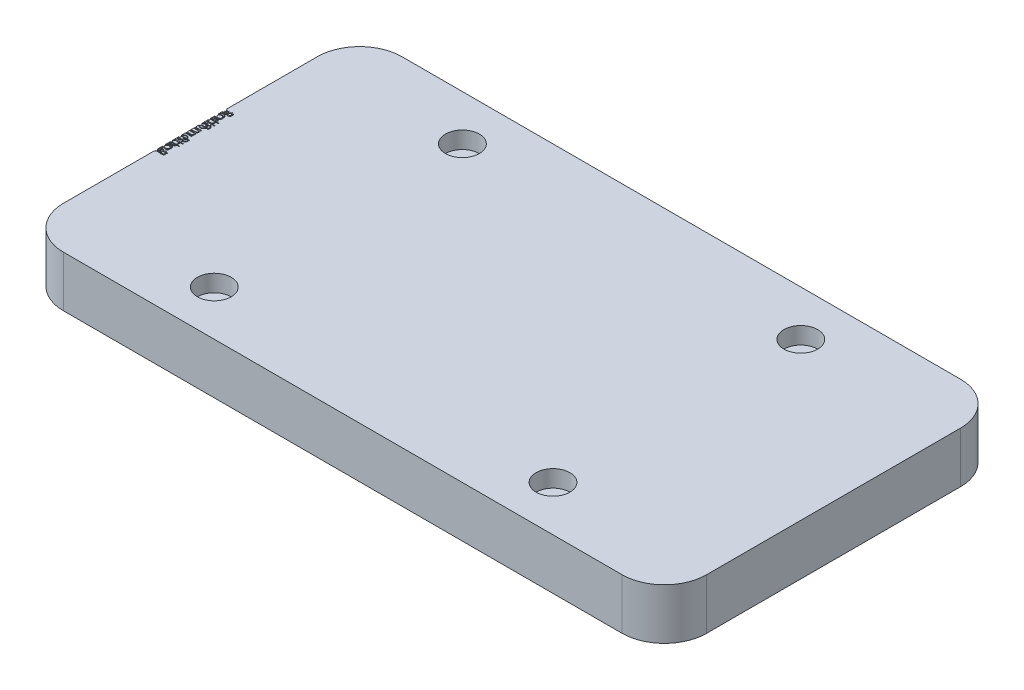
from build123d import *

# Parameters (mm, degrees)
SKETCH1_W           = 965.2
SKETCH1_H           = 508
BOSS_EXTRUDE1_DEPTH = 76.2
FILLET1_R           = 63.5
SKETCH3_R           = 25.4
CUT_EXTRUDE2_DEPTH  = 25.4


with BuildPart() as part:
    # Sketch1 → Boss-Extrude1 (new body)
    with BuildSketch(Plane(origin=(0, 0, 0), x_dir=(1, 0, 0), z_dir=(0, 1, 0))):
        Rectangle(SKETCH1_W, SKETCH1_H)
    extrude(amount=BOSS_EXTRUDE1_DEPTH)

    # Fillet1
    fillet1_edges = [part.edges().sort_by_distance(p)[0] for p in [
        (482.6, 38.1, 254),
        (-482.6, 38.1, 254),
        (-482.6, 38.1, -254),
        (482.6, 38.1, -254),
    ]]
    fillet(fillet1_edges, radius=FILLET1_R)

    # Sketch3 → Cut-Extrude2 (cut)
    with BuildSketch(Plane(origin=(0, 76.2, 0), x_dir=(1, 0, 0), z_dir=(0, 1, 0))):
        with Locations((-260.576021006, -186.128451286)):
            Circle(SKETCH3_R)
        with Locations((247.423936981, -185.921848446)):
            Circle(SKETCH3_R)
        with BuildLine():
            Line((-469.9, 52.672435897), (-469.9, 50.194511218))
            add(Edge.make_bspline(
                [(-469.9, 50.194511218), (-469.900637723, 50.073213597), (-469.901873789, 49.83810862), (-469.921044007, 49.496226645), (-469.947183038, 49.176009532), (-469.988657946, 48.877364415), (-470.038702394, 48.600429295), (-470.099306127, 48.344369583), (-470.171974125, 48.109999529), (-470.287530631, 47.830190457), (-470.459246128, 47.511164059), (-470.712986921, 47.165729891), (-471.023347573, 46.870348794), (-471.37344178, 46.615672729), (-471.758563009, 46.41319438), (-472.169532065, 46.266711502), (-472.6010481, 46.173972925), (-472.897296203, 46.164435464), (-473.047015224, 46.159615385)],
                knots=[0, 0, 0, 0, 0.000363838, 0.000705208, 0.00102698, 0.001327407, 0.00160934, 0.001870971, 0.002116378, 0.002344566, 0.002778261, 0.003200071, 0.003624679, 0.004058247, 0.004495235, 0.00492495, 0.005364021, 0.005812651, 0.005812651, 0.005812651, 0.005812651], degree=3))
            add(Edge.make_bspline(
                [(-473.047015224, 46.159615385), (-473.187292547, 46.163505539), (-473.462950716, 46.171150059), (-473.86548182, 46.246739197), (-474.250235763, 46.359280642), (-474.612469325, 46.522657567), (-474.947527019, 46.732810851), (-475.253417612, 46.985706072), (-475.5227281, 47.286810892), (-475.672659667, 47.512768065), (-475.748818109, 47.627544071)],
                knots=[0, 0, 0, 0, 0.000420396, 0.000826117, 0.00122453, 0.001620785, 0.002013965, 0.002407779, 0.002807724, 0.003220601, 0.003220601, 0.003220601, 0.003220601], degree=3))
            add(Edge.make_bspline(
                [(-475.748818109, 47.627544071), (-475.804165504, 47.483246357), (-475.91005878, 47.207169085), (-476.09829553, 46.826977114), (-476.300723621, 46.498102621), (-476.522955272, 46.220183613), (-476.765492883, 45.986079858), (-477.02347977, 45.775849827), (-477.30961699, 45.599724195), (-477.615756983, 45.448417432), (-477.939751109, 45.329340595), (-478.280117616, 45.24508592), (-478.63305059, 45.193315523), (-478.873610275, 45.186256112), (-478.995052083, 45.182692308)],
                knots=[0, 0, 0, 0, 0.000463447, 0.000886689, 0.0012707, 0.001619943, 0.001950965, 0.002280342, 0.002616352, 0.002956544, 0.003303444, 0.003649597, 0.004006864, 0.004371102, 0.004371102, 0.004371102, 0.004371102], degree=3))
            add(Edge.make_bspline(
                [(-478.995052083, 45.182692308), (-479.119028316, 45.186237976), (-479.362955028, 45.193214177), (-479.721305128, 45.244651328), (-480.063714462, 45.331828482), (-480.392617608, 45.451614654), (-480.70615286, 45.60883896), (-481.008246984, 45.796052137), (-481.290852396, 46.023914301), (-481.560689765, 46.277898937), (-481.803163144, 46.565563859), (-482.019031781, 46.875886763), (-482.197376027, 47.213331113), (-482.345316936, 47.572664039), (-482.459970385, 47.956273322), (-482.539568126, 48.362736629), (-482.593326065, 48.792142289), (-482.597737607, 49.086819793), (-482.6, 49.237940705)],
                knots=[0, 0, 0, 0, 0.000371861, 0.000731647, 0.001083355, 0.001430255, 0.001779543, 0.002133891, 0.002494262, 0.002866749, 0.003243967, 0.003620798, 0.003998668, 0.004386545, 0.004784958, 0.005197576, 0.005627998, 0.006081099, 0.006081099, 0.006081099, 0.006081099], degree=3))
            Line((-482.6, 49.237940705), (-482.6, 52.672435897))
            Line((-482.6, 52.672435897), (-469.9, 52.672435897))
        make_face()
        with BuildLine():
            Line((-471.202564103, 51.532692308), (-475.273076923, 51.532692308))
            Line((-475.273076923, 51.532692308), (-475.273076923, 50.766927083))
            add(Edge.make_bspline(
                [(-475.273076923, 50.766927083), (-475.27163785, 50.654989018), (-475.268857267, 50.438701864), (-475.260641171, 50.124651579), (-475.238643183, 49.833867594), (-475.215376682, 49.565347919), (-475.179551031, 49.32089229), (-475.1357105, 49.099682337), (-475.089750465, 48.8997309), (-475.011368955, 48.669247787), (-474.896703811, 48.407882991), (-474.714568466, 48.131029112), (-474.503524996, 47.882997153), (-474.255517346, 47.675893594), (-473.984747936, 47.504996957), (-473.691192628, 47.390947958), (-473.386311721, 47.310054501), (-473.176458844, 47.30296067), (-473.069911859, 47.299358974)],
                knots=[0, 0, 0, 0, 0.000335856, 0.000648942, 0.000942217, 0.001210553, 0.001457367, 0.001682887, 0.001887127, 0.002072164, 0.002412623, 0.002740048, 0.003062904, 0.003386041, 0.003705876, 0.004018621, 0.004327755, 0.004646587, 0.004646587, 0.004646587, 0.004646587], degree=3))
            add(Edge.make_bspline(
                [(-473.069911859, 47.299358974), (-472.999390861, 47.301160334), (-472.861056222, 47.304693898), (-472.660172947, 47.336853528), (-472.468824541, 47.383517465), (-472.291411885, 47.456420771), (-472.122892405, 47.544575936), (-471.970751178, 47.659249808), (-471.826653001, 47.788755491), (-471.695888802, 47.94084731), (-471.578723568, 48.114788827), (-471.475628439, 48.312237386), (-471.394304052, 48.535550624), (-471.321351749, 48.779665166), (-471.270730801, 49.048487848), (-471.228404946, 49.339391905), (-471.206889543, 49.654845166), (-471.204038075, 49.873085331), (-471.202564103, 49.985897436)],
                knots=[0, 0, 0, 0, 0.000211403, 0.00041469, 0.000609058, 0.000800861, 0.000988675, 0.001177964, 0.00137066, 0.001569065, 0.001777927, 0.001998675, 0.002235397, 0.002489804, 0.002762221, 0.003055088, 0.003371383, 0.00370983, 0.00370983, 0.00370983, 0.00370983], degree=3))
            Line((-471.202564103, 49.985897436), (-471.202564103, 51.532692308))
        make_face(mode=Mode.SUBTRACT)
        with BuildLine():
            Line((-476.575641026, 51.532692308), (-481.297435897, 51.532692308))
            Line((-481.297435897, 51.532692308), (-481.297435897, 49.909575321))
            add(Edge.make_bspline(
                [(-481.297435897, 49.909575321), (-481.296048306, 49.793391785), (-481.293373906, 49.569463336), (-481.284547792, 49.246160825), (-481.264893346, 48.947317605), (-481.232851357, 48.672761709), (-481.199556938, 48.420076298), (-481.153475853, 48.191771808), (-481.101087231, 47.98749823), (-481.020013357, 47.750667938), (-480.894278648, 47.483810583), (-480.703462766, 47.196432078), (-480.479128443, 46.938377978), (-480.21621688, 46.721754486), (-479.932509836, 46.5428753), (-479.629491192, 46.41741689), (-479.316405145, 46.33674893), (-479.102385409, 46.327216513), (-478.995052083, 46.322435897)],
                knots=[0, 0, 0, 0, 0.000348575, 0.000671832, 0.000970183, 0.001246634, 0.001501003, 0.001734503, 0.001944924, 0.002133185, 0.002484838, 0.002826351, 0.003165238, 0.003506608, 0.003844778, 0.004167484, 0.004487107, 0.004808668, 0.004808668, 0.004808668, 0.004808668], degree=3))
            add(Edge.make_bspline(
                [(-478.995052083, 46.322435897), (-478.927938995, 46.32341304), (-478.794795357, 46.325351565), (-478.599284527, 46.355686208), (-478.409054527, 46.398005015), (-478.226981914, 46.459286285), (-478.050103978, 46.536557), (-477.881501654, 46.633528815), (-477.717143599, 46.74551289), (-477.509596623, 46.920692987), (-477.270385861, 47.175255019), (-477.036215676, 47.537068916), (-476.847354019, 47.94844254), (-476.767164842, 48.246811706), (-476.725741186, 48.400941506)],
                knots=[0, 0, 0, 0, 0.000201126, 0.000399009, 0.000592174, 0.000785255, 0.00097434, 0.001170299, 0.001367887, 0.001570168, 0.001984172, 0.002410363, 0.00285778, 0.003335876, 0.003335876, 0.003335876, 0.003335876], degree=3))
            add(Edge.make_bspline(
                [(-476.725741186, 48.400941506), (-476.713203324, 48.462732739), (-476.686018654, 48.596708878), (-476.657341193, 48.815177494), (-476.631616576, 49.065426833), (-476.613087666, 49.346387285), (-476.593197204, 49.659176266), (-476.585737067, 50.00369329), (-476.576631577, 50.380181916), (-476.575979656, 50.641411701), (-476.575641026, 50.777103365)],
                knots=[0, 0, 0, 0, 0.000189102, 0.000410011, 0.000660625, 0.000943749, 0.001254636, 0.001600779, 0.001977379, 0.002384439, 0.002384439, 0.002384439, 0.002384439], degree=3))
            Line((-476.575641026, 50.777103365), (-476.575641026, 51.532692308))
        make_face(mode=Mode.SUBTRACT)
        with BuildLine():
            add(Edge.make_bspline(
                [(-473.156410256, 38.420552885), (-473.16010738, 38.2464088), (-473.167356535, 37.90495481), (-473.245216359, 37.404970266), (-473.363285809, 36.928198741), (-473.529483921, 36.472595029), (-473.747542335, 36.04192789), (-474.011239846, 35.632352177), (-474.322360513, 35.244688492), (-474.563165778, 35.012386046), (-474.685396635, 34.894471154)],
                knots=[0, 0, 0, 0, 0.000522037, 0.001023587, 0.001514124, 0.001993828, 0.002475095, 0.002959197, 0.003453068, 0.003962168, 0.003962168, 0.003962168, 0.003962168], degree=3))
            add(Edge.make_bspline(
                [(-474.685396635, 34.894471154), (-474.802287383, 34.792936635), (-475.033806722, 34.591832569), (-475.409202803, 34.333965533), (-475.797968311, 34.111818729), (-476.205265754, 33.93379027), (-476.62753956, 33.793418899), (-477.066241144, 33.693757658), (-477.520401661, 33.634477922), (-477.828844159, 33.6264843), (-477.98505609, 33.622435897)],
                knots=[0, 0, 0, 0, 0.000464173, 0.000919362, 0.001363665, 0.001805638, 0.002250531, 0.002696738, 0.003153347, 0.003621898, 0.003621898, 0.003621898, 0.003621898], degree=3))
            add(Edge.make_bspline(
                [(-477.98505609, 33.622435897), (-478.142173442, 33.62599675), (-478.452644658, 33.63303316), (-478.909914924, 33.699594284), (-479.35330758, 33.803121361), (-479.78096622, 33.951282625), (-480.194198376, 34.141267681), (-480.591198043, 34.373099921), (-480.972752756, 34.648404287), (-481.335606158, 34.960480646), (-481.670076683, 35.305365585), (-481.96141292, 35.679593572), (-482.212062, 36.07608169), (-482.411147062, 36.500242393), (-482.571623488, 36.946037888), (-482.682282312, 37.416303713), (-482.749787197, 37.910620352), (-482.758414963, 38.248184379), (-482.762820513, 38.420552885)],
                knots=[0, 0, 0, 0, 0.000471093, 0.000930902, 0.001383217, 0.001835375, 0.002286164, 0.002745627, 0.00321231, 0.003695764, 0.00417976, 0.00465101, 0.005116193, 0.005583894, 0.006053824, 0.006535131, 0.007030572, 0.007547526, 0.007547526, 0.007547526, 0.007547526], degree=3))
            add(Edge.make_bspline(
                [(-482.762820513, 38.420552885), (-482.758378512, 38.593757604), (-482.749678628, 38.932987796), (-482.682784452, 39.429165746), (-482.570441145, 39.901411537), (-482.413133726, 40.349315748), (-482.210426778, 40.773474731), (-481.962388173, 41.171426887), (-481.669929156, 41.545831391), (-481.335646131, 41.890824457), (-480.972742457, 42.202871825), (-480.591200716, 42.478183672), (-480.19419768, 42.710013968), (-479.780966406, 42.899999534), (-479.35330753, 43.048160661), (-478.909914938, 43.151687775), (-478.452644654, 43.218248889), (-478.142173441, 43.225285301), (-477.98505609, 43.228846154)],
                knots=[0, 0, 0, 0, 0.000519495, 0.001017458, 0.001498765, 0.001973491, 0.002438896, 0.002906237, 0.003377488, 0.003861484, 0.004344937, 0.00481162, 0.005271084, 0.005721873, 0.006174031, 0.006626346, 0.007086155, 0.007557247, 0.007557247, 0.007557247, 0.007557247], degree=3))
            add(Edge.make_bspline(
                [(-477.98505609, 43.228846154), (-477.829693195, 43.224770142), (-477.522101363, 43.216700339), (-477.0687946, 43.157480206), (-476.630835503, 43.05820773), (-476.210191633, 42.917668091), (-475.80467905, 42.737998684), (-475.414952949, 42.518973439), (-475.041254359, 42.258476001), (-474.81003424, 42.058171777), (-474.693028846, 41.956810897)],
                knots=[0, 0, 0, 0, 0.00046601, 0.000922619, 0.001368826, 0.001811304, 0.00225095, 0.002697469, 0.003150571, 0.003614743, 0.003614743, 0.003614743, 0.003614743], degree=3))
            add(Edge.make_bspline(
                [(-474.693028846, 41.956810897), (-474.569758563, 41.839064017), (-474.32732586, 41.607494057), (-474.016819049, 41.218040861), (-473.749566262, 40.810227001), (-473.531617589, 40.376781912), (-473.363587363, 39.91991136), (-473.244665292, 39.439596373), (-473.16770093, 38.937791986), (-473.160211321, 38.594684168), (-473.156410256, 38.420552885)],
                knots=[0, 0, 0, 0, 0.000510896, 0.001004767, 0.001490251, 0.001971518, 0.002456876, 0.002947413, 0.003453996, 0.003976033, 0.003976033, 0.003976033, 0.003976033], degree=3))
        make_face()
        with BuildLine():
            add(Edge.make_bspline(
                [(-474.296153846, 38.425641026), (-474.299654125, 38.548785934), (-474.306564324, 38.791896785), (-474.359117476, 39.149746988), (-474.442394232, 39.494236739), (-474.560663151, 39.826063577), (-474.713562546, 40.143944109), (-474.900302429, 40.448228095), (-475.121877393, 40.738098032), (-475.373883427, 41.011327095), (-475.647606173, 41.26502737), (-475.941941749, 41.484244379), (-476.24844624, 41.670992851), (-476.568710633, 41.826402283), (-476.905767983, 41.942190335), (-477.255857398, 42.026272442), (-477.619676934, 42.078779516), (-477.867004152, 42.085624269), (-477.992688301, 42.089102564)],
                knots=[0, 0, 0, 0, 0.00036932, 0.000729106, 0.001082667, 0.001431094, 0.00178384, 0.002139009, 0.002500276, 0.002876601, 0.003252925, 0.003618254, 0.003975594, 0.00432834, 0.004683965, 0.005042471, 0.005407295, 0.005784238, 0.005784238, 0.005784238, 0.005784238], degree=3))
            add(Edge.make_bspline(
                [(-477.992688301, 42.089102564), (-478.155081404, 42.083287475), (-478.477401347, 42.071745611), (-478.951953328, 41.977411514), (-479.408393042, 41.820718181), (-479.841224834, 41.604648572), (-480.242390724, 41.338552349), (-480.603120985, 41.027407388), (-480.90950441, 40.666912005), (-481.167178029, 40.269341758), (-481.370095762, 39.840330724), (-481.51561476, 39.387071454), (-481.608937334, 38.913691013), (-481.618322478, 38.589748136), (-481.623076923, 38.425641026)],
                knots=[0, 0, 0, 0, 0.000486876, 0.000966357, 0.001445055, 0.001930872, 0.002413502, 0.002885933, 0.003355036, 0.003827829, 0.004303516, 0.004774169, 0.005253171, 0.005744974, 0.005744974, 0.005744974, 0.005744974], degree=3))
            add(Edge.make_bspline(
                [(-481.623076923, 38.425641026), (-481.618350018, 38.261524476), (-481.60901924, 37.937562966), (-481.515141956, 37.463523876), (-481.37072853, 37.009022368), (-481.166948845, 36.579565272), (-480.910478348, 36.181813971), (-480.601375547, 35.823892772), (-480.243339018, 35.510068273), (-479.841756752, 35.243708566), (-479.407720151, 35.031120436), (-478.952037431, 34.873690221), (-478.477379928, 34.779582363), (-478.155074228, 34.768009962), (-477.992688301, 34.762179487)],
                knots=[0, 0, 0, 0, 0.000491802, 0.000970804, 0.001443878, 0.001919565, 0.002392359, 0.002859533, 0.003333639, 0.003816269, 0.004300959, 0.004779657, 0.005259139, 0.005746014, 0.005746014, 0.005746014, 0.005746014], degree=3))
            add(Edge.make_bspline(
                [(-477.992688301, 34.762179487), (-477.866994116, 34.765631901), (-477.61964715, 34.772425726), (-477.255971253, 34.825303231), (-476.905075553, 34.908079203), (-476.570068953, 35.028937645), (-476.246882051, 35.179013335), (-475.942862132, 35.37030468), (-475.647419061, 35.58850062), (-475.374048409, 35.842666429), (-475.12095662, 36.115864731), (-474.901109577, 36.407912331), (-474.713455907, 36.712337635), (-474.560644321, 37.030318625), (-474.442849452, 37.361394555), (-474.35875471, 37.704838417), (-474.306755938, 38.061103889), (-474.29971048, 38.303351474), (-474.296153846, 38.425641026)],
                knots=[0, 0, 0, 0, 0.000376943, 0.000741767, 0.001100273, 0.001456743, 0.001808396, 0.002167065, 0.002532393, 0.002908718, 0.003285043, 0.003648338, 0.004003507, 0.004356253, 0.004704679, 0.00505577, 0.005415556, 0.005782335, 0.005782335, 0.005782335, 0.005782335], degree=3))
        make_face(mode=Mode.SUBTRACT)
        Polygon((-469.574358974, 30.203205128), (-469.574358974, 29.063461538), (-473.319230769, 29.063461538), (-473.319230769, 27.43525641), (-474.458974359, 27.43525641), (-474.458974359, 29.063461538), (-482.6, 29.063461538), (-482.6, 30.203205128), (-474.458974359, 30.203205128), (-474.458974359, 31.831410256), (-473.319230769, 31.831410256), (-473.319230769, 30.203205128), align=None)
        Polygon((-469.574358974, 24.178846154), (-469.574358974, 23.039102564), (-473.319230769, 23.039102564), (-473.319230769, 21.410897436), (-474.458974359, 21.410897436), (-474.458974359, 23.039102564), (-482.6, 23.039102564), (-482.6, 24.178846154), (-474.458974359, 24.178846154), (-474.458974359, 25.807051282), (-473.319230769, 25.807051282), (-473.319230769, 24.178846154), align=None)
        with BuildLine():
            add(Edge.make_bspline(
                [(-473.156410256, 14.811578526), (-473.16010738, 14.637434441), (-473.167356535, 14.295980451), (-473.245216359, 13.795995907), (-473.363285809, 13.319224382), (-473.529483921, 12.86362067), (-473.747542335, 12.432953531), (-474.011239846, 12.023377818), (-474.322360513, 11.635714133), (-474.563165778, 11.403411687), (-474.685396635, 11.285496795)],
                knots=[0, 0, 0, 0, 0.000522037, 0.001023587, 0.001514124, 0.001993828, 0.002475095, 0.002959197, 0.003453068, 0.003962168, 0.003962168, 0.003962168, 0.003962168], degree=3))
            add(Edge.make_bspline(
                [(-474.685396635, 11.285496795), (-474.802287383, 11.183962276), (-475.033806722, 10.98285821), (-475.409202803, 10.724991174), (-475.797968311, 10.50284437), (-476.205265754, 10.324815911), (-476.62753956, 10.18444454), (-477.066241144, 10.084783299), (-477.520401661, 10.025503564), (-477.828844159, 10.017509941), (-477.98505609, 10.013461538)],
                knots=[0, 0, 0, 0, 0.000464173, 0.000919362, 0.001363665, 0.001805638, 0.002250531, 0.002696738, 0.003153347, 0.003621898, 0.003621898, 0.003621898, 0.003621898], degree=3))
            add(Edge.make_bspline(
                [(-477.98505609, 10.013461538), (-478.142173442, 10.017022391), (-478.452644658, 10.024058801), (-478.909914924, 10.090619925), (-479.35330758, 10.194147002), (-479.78096622, 10.342308266), (-480.194198376, 10.532293322), (-480.591198043, 10.764125562), (-480.972752756, 11.039429928), (-481.335606158, 11.351506287), (-481.670076683, 11.696391226), (-481.96141292, 12.070619213), (-482.212062, 12.467107331), (-482.411147062, 12.891268034), (-482.571623488, 13.337063529), (-482.682282312, 13.807329354), (-482.749787197, 14.301645993), (-482.758414963, 14.63921002), (-482.762820513, 14.811578526)],
                knots=[0, 0, 0, 0, 0.000471093, 0.000930902, 0.001383217, 0.001835375, 0.002286164, 0.002745627, 0.00321231, 0.003695764, 0.00417976, 0.00465101, 0.005116193, 0.005583894, 0.006053824, 0.006535131, 0.007030572, 0.007547526, 0.007547526, 0.007547526, 0.007547526], degree=3))
            add(Edge.make_bspline(
                [(-482.762820513, 14.811578526), (-482.758378512, 14.984783245), (-482.749678628, 15.324013437), (-482.682784452, 15.820191387), (-482.570441145, 16.292437178), (-482.413133726, 16.740341389), (-482.210426778, 17.164500372), (-481.962388173, 17.562452528), (-481.669929156, 17.936857032), (-481.335646131, 18.281850098), (-480.972742457, 18.593897467), (-480.591200716, 18.869209313), (-480.19419768, 19.101039609), (-479.780966406, 19.291025175), (-479.35330753, 19.439186302), (-478.909914938, 19.542713416), (-478.452644654, 19.60927453), (-478.142173441, 19.616310942), (-477.98505609, 19.619871795)],
                knots=[0, 0, 0, 0, 0.000519495, 0.001017458, 0.001498765, 0.001973491, 0.002438896, 0.002906237, 0.003377488, 0.003861484, 0.004344937, 0.00481162, 0.005271084, 0.005721873, 0.006174031, 0.006626346, 0.007086155, 0.007557247, 0.007557247, 0.007557247, 0.007557247], degree=3))
            add(Edge.make_bspline(
                [(-477.98505609, 19.619871795), (-477.829693195, 19.615795783), (-477.522101363, 19.60772598), (-477.0687946, 19.548505847), (-476.630835503, 19.449233371), (-476.210191633, 19.308693732), (-475.80467905, 19.129024325), (-475.414952949, 18.90999908), (-475.041254359, 18.649501642), (-474.81003424, 18.449197418), (-474.693028846, 18.347836538)],
                knots=[0, 0, 0, 0, 0.00046601, 0.000922619, 0.001368826, 0.001811304, 0.00225095, 0.002697469, 0.003150571, 0.003614743, 0.003614743, 0.003614743, 0.003614743], degree=3))
            add(Edge.make_bspline(
                [(-474.693028846, 18.347836538), (-474.569758563, 18.230089658), (-474.32732586, 17.998519698), (-474.016819049, 17.609066502), (-473.749566262, 17.201252642), (-473.531617589, 16.767807553), (-473.363587363, 16.310937001), (-473.244665292, 15.830622014), (-473.16770093, 15.328817627), (-473.160211321, 14.985709809), (-473.156410256, 14.811578526)],
                knots=[0, 0, 0, 0, 0.000510896, 0.001004767, 0.001490251, 0.001971518, 0.002456876, 0.002947413, 0.003453996, 0.003976033, 0.003976033, 0.003976033, 0.003976033], degree=3))
        make_face()
        with BuildLine():
            add(Edge.make_bspline(
                [(-474.296153846, 14.816666667), (-474.299654125, 14.939811575), (-474.306564324, 15.182922426), (-474.359117476, 15.540772629), (-474.442394232, 15.88526238), (-474.560663151, 16.217089218), (-474.713562546, 16.53496975), (-474.900302429, 16.839253736), (-475.121877393, 17.129123673), (-475.373883427, 17.402352736), (-475.647606173, 17.656053011), (-475.941941749, 17.87527002), (-476.24844624, 18.062018492), (-476.568710633, 18.217427924), (-476.905767983, 18.333215976), (-477.255857398, 18.417298083), (-477.619676934, 18.469805157), (-477.867004152, 18.47664991), (-477.992688301, 18.480128205)],
                knots=[0, 0, 0, 0, 0.00036932, 0.000729106, 0.001082667, 0.001431094, 0.00178384, 0.002139009, 0.002500276, 0.002876601, 0.003252925, 0.003618254, 0.003975594, 0.00432834, 0.004683965, 0.005042471, 0.005407295, 0.005784238, 0.005784238, 0.005784238, 0.005784238], degree=3))
            add(Edge.make_bspline(
                [(-477.992688301, 18.480128205), (-478.155081404, 18.474313116), (-478.477401347, 18.462771252), (-478.951953328, 18.368437155), (-479.408393042, 18.211743822), (-479.841224834, 17.995674213), (-480.242390724, 17.72957799), (-480.603120985, 17.418433029), (-480.90950441, 17.057937646), (-481.167178029, 16.660367399), (-481.370095762, 16.231356365), (-481.51561476, 15.778097095), (-481.608937334, 15.304716654), (-481.618322478, 14.980773777), (-481.623076923, 14.816666667)],
                knots=[0, 0, 0, 0, 0.000486876, 0.000966357, 0.001445055, 0.001930872, 0.002413502, 0.002885933, 0.003355036, 0.003827829, 0.004303516, 0.004774169, 0.005253171, 0.005744974, 0.005744974, 0.005744974, 0.005744974], degree=3))
            add(Edge.make_bspline(
                [(-481.623076923, 14.816666667), (-481.618350018, 14.652550117), (-481.60901924, 14.328588607), (-481.515141956, 13.854549517), (-481.37072853, 13.400048009), (-481.166948845, 12.970590913), (-480.910478348, 12.572839612), (-480.601375547, 12.214918413), (-480.243339018, 11.901093914), (-479.841756752, 11.634734207), (-479.407720151, 11.422146077), (-478.952037431, 11.264715862), (-478.477379928, 11.170608004), (-478.155074228, 11.159035603), (-477.992688301, 11.153205128)],
                knots=[0, 0, 0, 0, 0.000491802, 0.000970804, 0.001443878, 0.001919565, 0.002392359, 0.002859533, 0.003333639, 0.003816269, 0.004300959, 0.004779657, 0.005259139, 0.005746014, 0.005746014, 0.005746014, 0.005746014], degree=3))
            add(Edge.make_bspline(
                [(-477.992688301, 11.153205128), (-477.866994116, 11.156657543), (-477.61964715, 11.163451367), (-477.255971253, 11.216328872), (-476.905075553, 11.299104844), (-476.570068953, 11.419963286), (-476.246882051, 11.570038976), (-475.942862132, 11.761330321), (-475.647419061, 11.979526262), (-475.374048409, 12.23369207), (-475.12095662, 12.506890372), (-474.901109577, 12.798937972), (-474.713455907, 13.103363276), (-474.560644321, 13.421344266), (-474.442849452, 13.752420196), (-474.35875471, 14.095864058), (-474.306755938, 14.45212953), (-474.29971048, 14.694377115), (-474.296153846, 14.816666667)],
                knots=[0, 0, 0, 0, 0.000376943, 0.000741767, 0.001100273, 0.001456743, 0.001808396, 0.002167065, 0.002532393, 0.002908718, 0.003285043, 0.003648338, 0.004003507, 0.004356253, 0.004704679, 0.00505577, 0.005415556, 0.005782335, 0.005782335, 0.005782335, 0.005782335], degree=3))
        make_face(mode=Mode.SUBTRACT)
        with BuildLine():
            Line((-473.319230769, 7.733974359), (-473.319230769, 6.594230769))
            Line((-473.319230769, 6.594230769), (-474.932171474, 6.594230769))
            add(Edge.make_bspline(
                [(-474.932171474, 6.594230769), (-474.791273804, 6.491377822), (-474.521757789, 6.29463563), (-474.162643957, 5.975110922), (-473.862891447, 5.650413433), (-473.70347612, 5.418225923), (-473.627063301, 5.30693109)],
                knots=[0, 0, 0, 0, 0.000523065, 0.001000544, 0.001440014, 0.001844593, 0.001844593, 0.001844593, 0.001844593], degree=3))
            add(Edge.make_bspline(
                [(-473.627063301, 5.30693109), (-473.554472405, 5.155022173), (-473.410558859, 4.853858365), (-473.264568516, 4.37699432), (-473.17485172, 3.889043377), (-473.162582165, 3.559539286), (-473.156410256, 3.393790064)],
                knots=[0, 0, 0, 0, 0.000504483, 0.001000153, 0.001491205, 0.001988237, 0.001988237, 0.001988237, 0.001988237], degree=3))
            add(Edge.make_bspline(
                [(-473.156410256, 3.393790064), (-473.160213234, 3.281696702), (-473.167739123, 3.059869966), (-473.216432883, 2.731119525), (-473.301616238, 2.411776028), (-473.417258721, 2.103910924), (-473.561781667, 1.815612695), (-473.727966348, 1.550807332), (-473.915682176, 1.312746551), (-474.132197651, 1.101815987), (-474.383799994, 0.912158622), (-474.677218777, 0.737699708), (-475.019058893, 0.576500073), (-475.267131638, 0.487159833), (-475.397736378, 0.440124199)],
                knots=[0, 0, 0, 0, 0.000336289, 0.000665498, 0.000994402, 0.001326109, 0.001650365, 0.00196022, 0.002262579, 0.002557626, 0.002864447, 0.003205638, 0.00358004, 0.003996312, 0.003996312, 0.003996312, 0.003996312], degree=3))
            add(Edge.make_bspline(
                [(-475.397736378, 0.440124199), (-475.308022058, 0.390371943), (-475.131476875, 0.292466492), (-474.881619735, 0.128071758), (-474.647915152, -0.044168554), (-474.430177334, -0.225722208), (-474.229482826, -0.41594885), (-474.045163374, -0.615742046), (-473.876444654, -0.823970598), (-473.679277577, -1.113484112), (-473.470668989, -1.489615426), (-473.287450246, -1.96397546), (-473.176580476, -2.458408649), (-473.163166988, -2.794529235), (-473.156410256, -2.963842147)],
                knots=[0, 0, 0, 0, 0.000307664, 0.00060544, 0.000896489, 0.00117825, 0.001455378, 0.001725434, 0.001993226, 0.002258555, 0.002775496, 0.00327962, 0.003779632, 0.004287153, 0.004287153, 0.004287153, 0.004287153], degree=3))
            add(Edge.make_bspline(
                [(-473.156410256, -2.963842147), (-473.162278458, -3.119440598), (-473.173763098, -3.423961874), (-473.263945701, -3.86729081), (-473.418804592, -4.280736789), (-473.630109502, -4.663467894), (-473.895645395, -5.008762074), (-474.211580892, -5.30890411), (-474.575681267, -5.562070857), (-474.91818934, -5.727456207), (-475.220577548, -5.839634451), (-475.478228948, -5.908799502), (-475.76180744, -5.969903538), (-476.071652103, -6.020635485), (-476.408857453, -6.057714231), (-476.77287166, -6.085185113), (-477.163977636, -6.10377818), (-477.433818166, -6.105091985), (-477.572916667, -6.105769231)],
                knots=[0, 0, 0, 0, 0.000466565, 0.000913113, 0.001350227, 0.001786362, 0.002219908, 0.002651786, 0.003088633, 0.003544881, 0.003788754, 0.004055396, 0.004344313, 0.004658833, 0.004996811, 0.005361688, 0.00575388, 0.006171138, 0.006171138, 0.006171138, 0.006171138], degree=3))
            Line((-477.572916667, -6.105769231), (-482.6, -6.105769231))
            Line((-482.6, -6.105769231), (-482.6, -4.966025641))
            Line((-482.6, -4.966025641), (-477.567828526, -4.966025641))
            add(Edge.make_bspline(
                [(-477.567828526, -4.966025641), (-477.449099586, -4.965743037), (-477.220920621, -4.965199915), (-476.893433154, -4.955425881), (-476.594916547, -4.93700974), (-476.325777816, -4.915475485), (-476.08538939, -4.885562216), (-475.874233933, -4.846932747), (-475.690651008, -4.806010714), (-475.487137469, -4.738026484), (-475.262645788, -4.629354036), (-475.020498721, -4.463845596), (-474.809883175, -4.255244038), (-474.625955815, -4.014118427), (-474.479428051, -3.738914352), (-474.370825447, -3.436874876), (-474.306624782, -3.109018712), (-474.299702905, -2.881870514), (-474.296153846, -2.765404647)],
                knots=[0, 0, 0, 0, 0.000356179, 0.000684522, 0.00098271, 0.001253352, 0.001494435, 0.001709014, 0.001897224, 0.002058125, 0.002351698, 0.002642446, 0.002933895, 0.003237152, 0.003549026, 0.00386528, 0.004197074, 0.004546205, 0.004546205, 0.004546205, 0.004546205], degree=3))
            add(Edge.make_bspline(
                [(-474.296153846, -2.765404647), (-474.301404377, -2.621489376), (-474.311811588, -2.336231236), (-474.414120997, -1.9205128), (-474.572201447, -1.522108751), (-474.797898525, -1.151728286), (-475.069462959, -0.81058508), (-475.392191988, -0.517023718), (-475.757343275, -0.274521475), (-476.095330634, -0.110313412), (-476.398931498, -0.006575205), (-476.664170458, 0.06192106), (-476.965637885, 0.115200786), (-477.301307916, 0.165168138), (-477.673491144, 0.19778075), (-478.080465913, 0.227420273), (-478.52345628, 0.241284546), (-478.830530264, 0.243223868), (-478.989963942, 0.244230769)],
                knots=[0, 0, 0, 0, 0.00043103, 0.000854356, 0.001276703, 0.001712571, 0.002150417, 0.002580817, 0.003015466, 0.003461513, 0.003703682, 0.003977036, 0.004282409, 0.004621688, 0.004994826, 0.005402838, 0.005845769, 0.006324081, 0.006324081, 0.006324081, 0.006324081], degree=3))
            Line((-478.989963942, 0.244230769), (-482.6, 0.244230769))
            Line((-482.6, 0.244230769), (-482.6, 1.383974359))
            Line((-482.6, 1.383974359), (-477.880749199, 1.383974359))
            add(Edge.make_bspline(
                [(-477.880749199, 1.383974359), (-477.747603363, 1.384249666), (-477.491444159, 1.384779328), (-477.124130383, 1.394660584), (-476.789942412, 1.412559128), (-476.489719357, 1.435676558), (-476.222645367, 1.460766867), (-475.989596539, 1.500472965), (-475.789603115, 1.541862623), (-475.568136131, 1.605027018), (-475.327898037, 1.714432761), (-475.069835268, 1.880850644), (-474.842404578, 2.08758805), (-474.649544521, 2.333215234), (-474.491460363, 2.610577289), (-474.375799414, 2.915732026), (-474.309088443, 3.246751616), (-474.300546688, 3.474897182), (-474.296153846, 3.592227564)],
                knots=[0, 0, 0, 0, 0.000399427, 0.000768458, 0.001102206, 0.001403279, 0.001671868, 0.001906502, 0.002112085, 0.002284369, 0.00259641, 0.002899837, 0.0032024, 0.003513901, 0.003832925, 0.004156593, 0.004488884, 0.004840711, 0.004840711, 0.004840711, 0.004840711], degree=3))
            add(Edge.make_bspline(
                [(-474.296153846, 3.592227564), (-474.30170723, 3.730172102), (-474.312774926, 4.005090667), (-474.412394718, 4.408957828), (-474.568438083, 4.798977253), (-474.784917965, 5.168927376), (-475.053066175, 5.508829898), (-475.36844262, 5.806405779), (-475.727125145, 6.056557236), (-476.061544998, 6.222535541), (-476.357552025, 6.329490603), (-476.609152387, 6.400884867), (-476.88887801, 6.460755974), (-477.19611684, 6.511503859), (-477.531506557, 6.54969092), (-477.894099288, 6.572538022), (-478.285040227, 6.592620948), (-478.554897149, 6.593681), (-478.694851763, 6.594230769)],
                knots=[0, 0, 0, 0, 0.000413269, 0.00082363, 0.001240306, 0.001670103, 0.002104775, 0.002534903, 0.002966121, 0.003412118, 0.003650339, 0.003909634, 0.004196066, 0.004508075, 0.004843526, 0.005208216, 0.005597866, 0.006017669, 0.006017669, 0.006017669, 0.006017669], degree=3))
            Line((-478.694851763, 6.594230769), (-482.6, 6.594230769))
            Line((-482.6, 6.594230769), (-482.6, 7.733974359))
            Line((-482.6, 7.733974359), (-473.319230769, 7.733974359))
        make_face()
        with BuildLine():
            Line((-469.9, -13.921153846), (-469.9, -16.399078526))
            add(Edge.make_bspline(
                [(-469.9, -16.399078526), (-469.900637723, -16.520376146), (-469.901873789, -16.755481124), (-469.921044007, -17.097363099), (-469.947183038, -17.417580212), (-469.988657946, -17.716225328), (-470.038702394, -17.993160448), (-470.099306127, -18.249220161), (-470.171974125, -18.483590214), (-470.287530631, -18.763399286), (-470.459246128, -19.082425685), (-470.712986921, -19.427859852), (-471.023347573, -19.723240949), (-471.37344178, -19.977917015), (-471.758563009, -20.180395363), (-472.169532065, -20.326878242), (-472.6010481, -20.419616818), (-472.897296203, -20.42915428), (-473.047015224, -20.433974359)],
                knots=[0, 0, 0, 0, 0.000363838, 0.000705208, 0.00102698, 0.001327407, 0.00160934, 0.001870971, 0.002116378, 0.002344566, 0.002778261, 0.003200071, 0.003624679, 0.004058247, 0.004495235, 0.00492495, 0.005364021, 0.005812651, 0.005812651, 0.005812651, 0.005812651], degree=3))
            add(Edge.make_bspline(
                [(-473.047015224, -20.433974359), (-473.187292547, -20.430084205), (-473.462950716, -20.422439685), (-473.86548182, -20.346850546), (-474.250235763, -20.234309102), (-474.612469325, -20.070932177), (-474.947527019, -19.860778893), (-475.253417612, -19.607883671), (-475.5227281, -19.306778851), (-475.672659667, -19.080821678), (-475.748818109, -18.966045673)],
                knots=[0, 0, 0, 0, 0.000420396, 0.000826117, 0.00122453, 0.001620785, 0.002013965, 0.002407779, 0.002807724, 0.003220601, 0.003220601, 0.003220601, 0.003220601], degree=3))
            add(Edge.make_bspline(
                [(-475.748818109, -18.966045673), (-475.804165504, -19.110343387), (-475.91005878, -19.386420659), (-476.09829553, -19.76661263), (-476.300723621, -20.095487122), (-476.522955272, -20.37340613), (-476.765492883, -20.607509886), (-477.02347977, -20.817739917), (-477.30961699, -20.993865548), (-477.615756983, -21.145172312), (-477.939751109, -21.264249148), (-478.280117616, -21.348503824), (-478.63305059, -21.400274221), (-478.873610275, -21.407333632), (-478.995052083, -21.410897436)],
                knots=[0, 0, 0, 0, 0.000463447, 0.000886689, 0.0012707, 0.001619943, 0.001950965, 0.002280342, 0.002616352, 0.002956544, 0.003303444, 0.003649597, 0.004006864, 0.004371102, 0.004371102, 0.004371102, 0.004371102], degree=3))
            add(Edge.make_bspline(
                [(-478.995052083, -21.410897436), (-479.119028316, -21.407351768), (-479.362955028, -21.400375567), (-479.721305128, -21.348938415), (-480.063714462, -21.261761261), (-480.392617608, -21.14197509), (-480.70615286, -20.984750784), (-481.008246984, -20.797537606), (-481.290852396, -20.569675443), (-481.560689765, -20.315690807), (-481.803163144, -20.028025884), (-482.019031781, -19.717702981), (-482.197376027, -19.380258631), (-482.345316936, -19.020925704), (-482.459970385, -18.637316422), (-482.539568126, -18.230853115), (-482.593326065, -17.801447455), (-482.597737607, -17.506769951), (-482.6, -17.355649038)],
                knots=[0, 0, 0, 0, 0.000371861, 0.000731647, 0.001083355, 0.001430255, 0.001779543, 0.002133891, 0.002494262, 0.002866749, 0.003243967, 0.003620798, 0.003998668, 0.004386545, 0.004784958, 0.005197576, 0.005627998, 0.006081099, 0.006081099, 0.006081099, 0.006081099], degree=3))
            Line((-482.6, -17.355649038), (-482.6, -13.921153846))
            Line((-482.6, -13.921153846), (-469.9, -13.921153846))
        make_face()
        with BuildLine():
            Line((-471.202564103, -15.060897436), (-475.273076923, -15.060897436))
            Line((-475.273076923, -15.060897436), (-475.273076923, -15.82666266))
            add(Edge.make_bspline(
                [(-475.273076923, -15.82666266), (-475.27163785, -15.938600726), (-475.268857267, -16.15488788), (-475.260641171, -16.468938165), (-475.238643183, -16.75972215), (-475.215376682, -17.028241824), (-475.179551031, -17.272697453), (-475.1357105, -17.493907406), (-475.089750465, -17.693858843), (-475.011368955, -17.924341957), (-474.896703811, -18.185706752), (-474.714568466, -18.462560632), (-474.503524996, -18.710592591), (-474.255517346, -18.917696149), (-473.984747936, -19.088592787), (-473.691192628, -19.202641786), (-473.386311721, -19.283535242), (-473.176458844, -19.290629073), (-473.069911859, -19.294230769)],
                knots=[0, 0, 0, 0, 0.000335856, 0.000648942, 0.000942217, 0.001210553, 0.001457367, 0.001682887, 0.001887127, 0.002072164, 0.002412623, 0.002740048, 0.003062904, 0.003386041, 0.003705876, 0.004018621, 0.004327755, 0.004646587, 0.004646587, 0.004646587, 0.004646587], degree=3))
            add(Edge.make_bspline(
                [(-473.069911859, -19.294230769), (-472.999390861, -19.29242941), (-472.861056222, -19.288895846), (-472.660172947, -19.256736215), (-472.468824541, -19.210072278), (-472.291411885, -19.137168973), (-472.122892405, -19.049013807), (-471.970751178, -18.934339936), (-471.826653001, -18.804834253), (-471.695888802, -18.652742434), (-471.578723568, -18.478800917), (-471.475628439, -18.281352358), (-471.394304052, -18.058039119), (-471.321351749, -17.813924578), (-471.270730801, -17.545101896), (-471.228404946, -17.254197838), (-471.206889543, -16.938744577), (-471.204038075, -16.720504413), (-471.202564103, -16.607692308)],
                knots=[0, 0, 0, 0, 0.000211403, 0.00041469, 0.000609058, 0.000800861, 0.000988675, 0.001177964, 0.00137066, 0.001569065, 0.001777927, 0.001998675, 0.002235397, 0.002489804, 0.002762221, 0.003055088, 0.003371383, 0.00370983, 0.00370983, 0.00370983, 0.00370983], degree=3))
            Line((-471.202564103, -16.607692308), (-471.202564103, -15.060897436))
        make_face(mode=Mode.SUBTRACT)
        with BuildLine():
            Line((-476.575641026, -15.060897436), (-481.297435897, -15.060897436))
            Line((-481.297435897, -15.060897436), (-481.297435897, -16.684014423))
            add(Edge.make_bspline(
                [(-481.297435897, -16.684014423), (-481.296048306, -16.800197959), (-481.293373906, -17.024126407), (-481.284547792, -17.347428918), (-481.264893346, -17.646272139), (-481.232851357, -17.920828035), (-481.199556938, -18.173513446), (-481.153475853, -18.401817936), (-481.101087231, -18.606091513), (-481.020013357, -18.842921805), (-480.894278648, -19.109779161), (-480.703462766, -19.397157666), (-480.479128443, -19.655211766), (-480.21621688, -19.871835258), (-479.932509836, -20.050714443), (-479.629491192, -20.176172853), (-479.316405145, -20.256840813), (-479.102385409, -20.266373231), (-478.995052083, -20.271153846)],
                knots=[0, 0, 0, 0, 0.000348575, 0.000671832, 0.000970183, 0.001246634, 0.001501003, 0.001734503, 0.001944924, 0.002133185, 0.002484838, 0.002826351, 0.003165238, 0.003506608, 0.003844778, 0.004167484, 0.004487107, 0.004808668, 0.004808668, 0.004808668, 0.004808668], degree=3))
            add(Edge.make_bspline(
                [(-478.995052083, -20.271153846), (-478.927938995, -20.270176703), (-478.794795357, -20.268238179), (-478.599284527, -20.237903535), (-478.409054527, -20.195584729), (-478.226981914, -20.134303459), (-478.050103978, -20.057032744), (-477.881501654, -19.960060928), (-477.717143599, -19.848076853), (-477.509596623, -19.672896756), (-477.270385861, -19.418334725), (-477.036215676, -19.056520827), (-476.847354019, -18.645147203), (-476.767164842, -18.346778038), (-476.725741186, -18.192648237)],
                knots=[0, 0, 0, 0, 0.000201126, 0.000399009, 0.000592174, 0.000785255, 0.00097434, 0.001170299, 0.001367887, 0.001570168, 0.001984172, 0.002410363, 0.00285778, 0.003335876, 0.003335876, 0.003335876, 0.003335876], degree=3))
            add(Edge.make_bspline(
                [(-476.725741186, -18.192648237), (-476.713203324, -18.130857004), (-476.686018654, -17.996880866), (-476.657341193, -17.77841225), (-476.631616576, -17.528162911), (-476.613087666, -17.247202459), (-476.593197204, -16.934413477), (-476.585737067, -16.589896454), (-476.576631577, -16.213407828), (-476.575979656, -15.952178043), (-476.575641026, -15.816486378)],
                knots=[0, 0, 0, 0, 0.000189102, 0.000410011, 0.000660625, 0.000943749, 0.001254636, 0.001600779, 0.001977379, 0.002384439, 0.002384439, 0.002384439, 0.002384439], degree=3))
            Line((-476.575641026, -15.816486378), (-476.575641026, -15.060897436))
        make_face(mode=Mode.SUBTRACT)
        with BuildLine():
            Line((-473.319230769, -33.133974359), (-482.6, -33.133974359))
            Line((-482.6, -33.133974359), (-482.6, -31.994230769))
            Line((-482.6, -31.994230769), (-480.994691506, -31.994230769))
            add(Edge.make_bspline(
                [(-480.994691506, -31.994230769), (-481.140017247, -31.865738032), (-481.423622258, -31.614982839), (-481.793024485, -31.196245747), (-482.100876673, -30.754230892), (-482.347208846, -30.287443581), (-482.533653478, -29.797280429), (-482.664766749, -29.285139257), (-482.750117907, -28.751702623), (-482.758548323, -28.387917233), (-482.762820513, -28.203565705)],
                knots=[0, 0, 0, 0, 0.000581525, 0.001134853, 0.001670493, 0.002193978, 0.002714177, 0.003239908, 0.003777815, 0.004330464, 0.004330464, 0.004330464, 0.004330464], degree=3))
            add(Edge.make_bspline(
                [(-482.762820513, -28.203565705), (-482.758371272, -28.039670113), (-482.749597172, -27.716460748), (-482.681506194, -27.241018787), (-482.57221429, -26.783460406), (-482.420029611, -26.343493993), (-482.219203492, -25.924100683), (-481.976176149, -25.522917305), (-481.689603982, -25.139007568), (-481.360715217, -24.779672632), (-481.003873066, -24.448356917), (-480.622160272, -24.158489129), (-480.220819651, -23.912816741), (-479.799964003, -23.710918038), (-479.359900972, -23.554678235), (-478.900932452, -23.445977607), (-478.423822141, -23.377960006), (-478.0989202, -23.369190351), (-477.934174679, -23.36474359)],
                knots=[0, 0, 0, 0, 0.000491539, 0.000969337, 0.001437681, 0.001901121, 0.002363134, 0.002829983, 0.003306234, 0.003797899, 0.004289405, 0.004765153, 0.005233324, 0.005698729, 0.006163013, 0.006631357, 0.007111675, 0.007605755, 0.007605755, 0.007605755, 0.007605755], degree=3))
            add(Edge.make_bspline(
                [(-477.934174679, -23.36474359), (-477.772834267, -23.369288978), (-477.453872976, -23.378274967), (-476.984785925, -23.445249797), (-476.532925832, -23.557788945), (-476.099966557, -23.716024301), (-475.684164428, -23.918030367), (-475.288772689, -24.167927764), (-474.90774296, -24.457691098), (-474.553294188, -24.79254774), (-474.227073739, -25.155107838), (-473.939805146, -25.541165512), (-473.697400903, -25.945907009), (-473.50034982, -26.370143892), (-473.343761034, -26.810872189), (-473.234603573, -27.271439878), (-473.17043646, -27.749752483), (-473.161130581, -28.074471713), (-473.156410256, -28.239182692)],
                knots=[0, 0, 0, 0, 0.000483915, 0.000956675, 0.001418211, 0.001878569, 0.002337102, 0.002802284, 0.003279574, 0.003770948, 0.004262797, 0.004741089, 0.005212298, 0.005675529, 0.006142212, 0.00661303, 0.007093003, 0.007587084, 0.007587084, 0.007587084, 0.007587084], degree=3))
            add(Edge.make_bspline(
                [(-473.156410256, -28.239182692), (-473.161601839, -28.428600982), (-473.171782286, -28.80004131), (-473.257405028, -29.344045397), (-473.400280382, -29.859150719), (-473.596643351, -30.348326412), (-473.855647739, -30.809674846), (-474.185320166, -31.237518049), (-474.578129273, -31.640469196), (-474.880724793, -31.87401753), (-475.036478365, -31.994230769)],
                knots=[0, 0, 0, 0, 0.000568018, 0.001113856, 0.00164714, 0.0021687, 0.002691579, 0.003228902, 0.003784797, 0.004374429, 0.004374429, 0.004374429, 0.004374429], degree=3))
            Line((-475.036478365, -31.994230769), (-473.319230769, -31.994230769))
            Line((-473.319230769, -31.994230769), (-473.319230769, -33.133974359))
        make_face()
        with BuildLine():
            add(Edge.make_bspline(
                [(-474.296153846, -28.254447115), (-474.302081554, -28.087843561), (-474.313781905, -27.758994643), (-474.405126653, -27.276236428), (-474.557104429, -26.814265162), (-474.764968939, -26.37542419), (-475.026281997, -25.966523509), (-475.34258701, -25.601430453), (-475.703825371, -25.275777064), (-476.113034185, -25.006532458), (-476.546723037, -24.779532469), (-477.00351655, -24.623866836), (-477.470741941, -24.520281871), (-477.787764072, -24.509765785), (-477.946895032, -24.504487179)],
                knots=[0, 0, 0, 0, 0.000499572, 0.000986075, 0.00146798, 0.001955041, 0.002439144, 0.00291901, 0.003400081, 0.003893297, 0.004384823, 0.004864351, 0.005337357, 0.005814076, 0.005814076, 0.005814076, 0.005814076], degree=3))
            add(Edge.make_bspline(
                [(-477.946895032, -24.504487179), (-478.105043672, -24.511316457), (-478.420721062, -24.524948244), (-478.889334644, -24.621136411), (-479.344289229, -24.787797896), (-479.783985621, -25.009616586), (-480.194034386, -25.284900558), (-480.562336723, -25.607851236), (-480.879910253, -25.977599895), (-481.145719396, -26.387387516), (-481.359683119, -26.824395153), (-481.51055822, -27.284177394), (-481.605827722, -27.758655724), (-481.617307849, -28.081854635), (-481.623076923, -28.244270833)],
                knots=[0, 0, 0, 0, 0.000474351, 0.000946844, 0.00142807, 0.001924131, 0.002420877, 0.002905754, 0.003389208, 0.003878212, 0.004367475, 0.004844547, 0.005326526, 0.005813402, 0.005813402, 0.005813402, 0.005813402], degree=3))
            add(Edge.make_bspline(
                [(-481.623076923, -28.244270833), (-481.617143831, -28.409196309), (-481.605373512, -28.736382472), (-481.512501127, -29.22027693), (-481.362412994, -29.690593974), (-481.151573362, -30.140337488), (-480.891468554, -30.558996438), (-480.585620252, -30.934270944), (-480.232900997, -31.254712997), (-479.842142562, -31.523344315), (-479.415767547, -31.735549593), (-478.959874571, -31.885220721), (-478.478046294, -31.977146756), (-478.148289709, -31.988457358), (-477.979967949, -31.994230769)],
                knots=[0, 0, 0, 0, 0.000494493, 0.000980996, 0.001472581, 0.001972237, 0.002467083, 0.002947879, 0.003419693, 0.003891781, 0.004366221, 0.004843293, 0.005327296, 0.005831946, 0.005831946, 0.005831946, 0.005831946], degree=3))
            add(Edge.make_bspline(
                [(-477.979967949, -31.994230769), (-477.851742156, -31.990748533), (-477.599353218, -31.983894389), (-477.228775519, -31.931532823), (-476.874144301, -31.848236354), (-476.535071409, -31.730876442), (-476.213487951, -31.576654826), (-475.906873159, -31.390845462), (-475.618083109, -31.169637123), (-475.347483526, -30.919761744), (-475.101904192, -30.64316652), (-474.885452628, -30.349043346), (-474.702275045, -30.038132234), (-474.555685066, -29.710651425), (-474.436261885, -29.369123202), (-474.357384938, -29.010274078), (-474.303050895, -28.637720598), (-474.298477069, -28.383550099), (-474.296153846, -28.254447115)],
                knots=[0, 0, 0, 0, 0.000384567, 0.00075695, 0.001120405, 0.001476029, 0.001831071, 0.002188411, 0.002549678, 0.002920537, 0.003291744, 0.003657604, 0.004014518, 0.00437203, 0.004732463, 0.005097819, 0.005472722, 0.005859722, 0.005859722, 0.005859722, 0.005859722], degree=3))
        make_face(mode=Mode.SUBTRACT)
        with BuildLine():
            Line((-475.331590545, -44.857051282), (-475.924358974, -43.90302484))
            add(Edge.make_bspline(
                [(-475.924358974, -43.90302484), (-475.794342074, -43.798419452), (-475.53842588, -43.592521507), (-475.208347081, -43.234881498), (-474.923692577, -42.85355166), (-474.694818221, -42.441342055), (-474.514145489, -42.001864293), (-474.388580315, -41.534212968), (-474.309655598, -41.038532377), (-474.300728172, -40.698651055), (-474.296153846, -40.524499199)],
                knots=[0, 0, 0, 0, 0.000500018, 0.000984201, 0.001455376, 0.001924625, 0.0023947, 0.002877329, 0.003374231, 0.003896386, 0.003896386, 0.003896386, 0.003896386], degree=3))
            add(Edge.make_bspline(
                [(-474.296153846, -40.524499199), (-474.299988906, -40.385311148), (-474.307541951, -40.111184066), (-474.354748145, -39.708750824), (-474.440546844, -39.325428479), (-474.553537052, -38.958764437), (-474.705189754, -38.61154842), (-474.888626282, -38.282807693), (-475.10462825, -37.971442698), (-475.351639551, -37.682399751), (-475.622947269, -37.418980615), (-475.909459797, -37.186008391), (-476.213183161, -36.991562078), (-476.528352835, -36.829475542), (-476.860390816, -36.707524586), (-477.205263322, -36.617844853), (-477.565239698, -36.56318144), (-477.810174822, -36.556558188), (-477.934174679, -36.553205128)],
                knots=[0, 0, 0, 0, 0.000417607, 0.000822467, 0.001213203, 0.001594593, 0.001971742, 0.002347585, 0.002722324, 0.003106715, 0.003486327, 0.003855437, 0.004212514, 0.004566359, 0.004916527, 0.005271332, 0.005634002, 0.006005863, 0.006005863, 0.006005863, 0.006005863], degree=3))
            add(Edge.make_bspline(
                [(-477.934174679, -36.553205128), (-478.096630072, -36.559646688), (-478.419351911, -36.572443014), (-478.895598608, -36.6731756), (-479.356923213, -36.837007715), (-479.797159837, -37.065638192), (-480.205338176, -37.350087016), (-480.574412112, -37.682003085), (-480.889015103, -38.068750132), (-481.152313476, -38.498976817), (-481.364830026, -38.964914976), (-481.51478995, -39.462871031), (-481.605811109, -39.98860449), (-481.617246487, -40.348589596), (-481.623076923, -40.53213141)],
                knots=[0, 0, 0, 0, 0.000487042, 0.000967521, 0.001453538, 0.001951916, 0.002450872, 0.002942536, 0.00343604, 0.003940876, 0.004452089, 0.004967958, 0.005497039, 0.006047406, 0.006047406, 0.006047406, 0.006047406], degree=3))
            add(Edge.make_bspline(
                [(-481.623076923, -40.53213141), (-481.618361605, -40.700334508), (-481.609094753, -41.03089823), (-481.530975372, -41.514105236), (-481.40309133, -41.974135198), (-481.224755571, -42.410971766), (-480.994241442, -42.823816712), (-480.709909593, -43.210002575), (-480.379939644, -43.57721378), (-480.124785862, -43.793102809), (-479.994871795, -43.90302484)],
                knots=[0, 0, 0, 0, 0.000504368, 0.000991217, 0.001464038, 0.001934113, 0.002403361, 0.00287864, 0.003370304, 0.003880319, 0.003880319, 0.003880319, 0.003880319], degree=3))
            Line((-479.994871795, -43.90302484), (-480.620713141, -44.857051282))
            add(Edge.make_bspline(
                [(-480.620713141, -44.857051282), (-480.7037731, -44.800489707), (-480.869617333, -44.687554293), (-481.103467527, -44.498775553), (-481.322310924, -44.295113527), (-481.526082186, -44.077525367), (-481.718355674, -43.848772485), (-481.893682441, -43.602900533), (-482.056499067, -43.344095247), (-482.204047321, -43.071169226), (-482.336385517, -42.786810371), (-482.450911782, -42.491010005), (-482.547743474, -42.185104351), (-482.626096004, -41.869780804), (-482.688082161, -41.544541766), (-482.729308087, -41.20963491), (-482.760053585, -40.865122908), (-482.761890207, -40.632270006), (-482.762820513, -40.514322917)],
                knots=[0, 0, 0, 0, 0.000301373, 0.000601746, 0.000900563, 0.001197523, 0.00149557, 0.001796341, 0.002102688, 0.002412323, 0.002726472, 0.003043012, 0.003363242, 0.003688416, 0.004017231, 0.004355822, 0.00470041, 0.005054118, 0.005054118, 0.005054118, 0.005054118], degree=3))
            add(Edge.make_bspline(
                [(-482.762820513, -40.514322917), (-482.75958644, -40.334306282), (-482.753247634, -39.981472372), (-482.683548314, -39.465044977), (-482.578473517, -38.971509708), (-482.427656604, -38.501034958), (-482.233510469, -38.053548295), (-481.996359114, -37.629463974), (-481.714227886, -37.230197437), (-481.392158366, -36.859654576), (-481.042896193, -36.519459815), (-480.666234289, -36.226914698), (-480.274738457, -35.974529949), (-479.863849285, -35.766391878), (-479.432012199, -35.609162332), (-478.982607662, -35.497262474), (-478.515646181, -35.426019353), (-478.197320045, -35.417686211), (-478.0359375, -35.413461538)],
                knots=[0, 0, 0, 0, 0.000539727, 0.001057868, 0.001560366, 0.002051951, 0.002537336, 0.003021411, 0.003507029, 0.004001247, 0.004492437, 0.004967259, 0.005429504, 0.005888015, 0.006345983, 0.006805052, 0.007275657, 0.007759573, 0.007759573, 0.007759573, 0.007759573], degree=3))
            add(Edge.make_bspline(
                [(-478.0359375, -35.413461538), (-477.926450413, -35.415159152), (-477.708662526, -35.418535985), (-477.384979654, -35.453624892), (-477.067029684, -35.506179893), (-476.755268932, -35.580790762), (-476.448754336, -35.674415223), (-476.149122852, -35.792083186), (-475.854631072, -35.92978814), (-475.568905026, -36.089997741), (-475.293674954, -36.266719452), (-475.030507891, -36.458756242), (-474.786143951, -36.669410082), (-474.554467361, -36.894224527), (-474.342395086, -37.13660555), (-474.140764842, -37.392037679), (-473.960022904, -37.666824216), (-473.791246347, -37.95396185), (-473.641231836, -38.253821557), (-473.511917623, -38.564292861), (-473.4014227, -38.883585472), (-473.313940564, -39.212188442), (-473.240580526, -39.547926537), (-473.194432823, -39.893443891), (-473.161825514, -40.247419117), (-473.158230351, -40.487108111), (-473.156410256, -40.608453526)],
                knots=[0, 0, 0, 0, 0.000328343, 0.000653128, 0.000975593, 0.001294618, 0.001614089, 0.001936293, 0.00225951, 0.002588651, 0.002918213, 0.003240307, 0.003565092, 0.003885322, 0.004207938, 0.004530584, 0.004860804, 0.005193727, 0.005529361, 0.005865766, 0.006202065, 0.006542115, 0.006885404, 0.007232239, 0.00758718, 0.007951124, 0.007951124, 0.007951124, 0.007951124], degree=3))
            add(Edge.make_bspline(
                [(-473.156410256, -40.608453526), (-473.159754515, -40.760418916), (-473.166426315, -41.063590103), (-473.222604916, -41.513311466), (-473.307233108, -41.956439027), (-473.432867416, -42.385055683), (-473.583842512, -42.793758182), (-473.756652978, -43.175591141), (-473.952460271, -43.524567652), (-474.17012918, -43.843929639), (-474.414408921, -44.134945024), (-474.689518846, -44.400733018), (-474.993794686, -44.646870782), (-475.218062656, -44.786412914), (-475.331590545, -44.857051282)],
                knots=[0, 0, 0, 0, 0.000455737, 0.000909195, 0.001357739, 0.001807838, 0.002247337, 0.002664013, 0.003063829, 0.003446295, 0.003821871, 0.004201484, 0.004592444, 0.004993246, 0.004993246, 0.004993246, 0.004993246], degree=3))
        make_face()
        Polygon((-469.574358974, -47.136538462), (-469.574358974, -48.276282051), (-477.104807692, -48.276282051), (-473.319230769, -52.499439103), (-473.319230769, -54.137820513), (-477.715384615, -49.237940705), (-482.6, -54.626282051), (-482.6, -52.990444712), (-478.323417468, -48.276282051), (-482.6, -48.276282051), (-482.6, -47.136538462), align=None)
    cut_extrude2 = extrude(amount=-CUT_EXTRUDE2_DEPTH, mode=Mode.SUBTRACT)

    # Mirror1: Cut-Extrude2 across plane
    add(cut_extrude2.mirror(Plane.XY), mode=Mode.SUBTRACT)


solid = part.part
